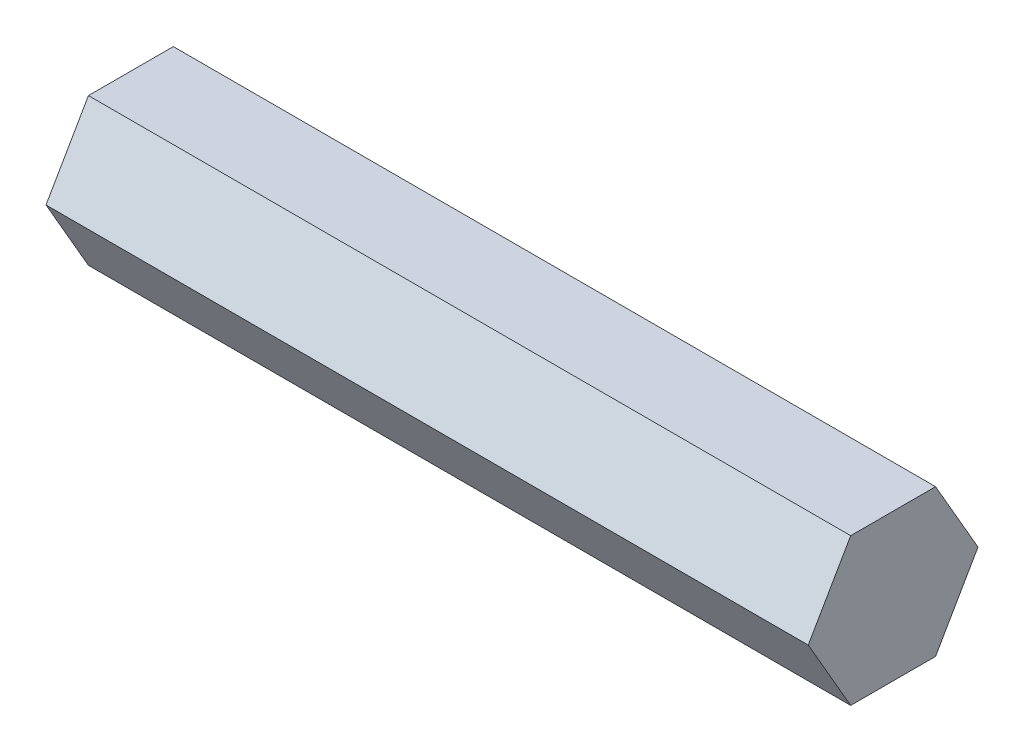
from build123d import *

# Parameters (mm, degrees)
BOSS_EXTRUDE1_DEPTH = 65.85


with BuildPart() as part:
    # Sketch1 → Boss-Extrude1 (new body)
    with BuildSketch(Plane(origin=(0, 0, 0), x_dir=(0, 0, -1), z_dir=(1, 0, 0))):
        Polygon((7.332348419, 0), (3.666174209, 6.35), (-3.666174209, 6.35), (-7.332348419, 0), (-3.666174209, -6.35), (3.666174209, -6.35), align=None)
    extrude(amount=BOSS_EXTRUDE1_DEPTH)


solid = part.part
